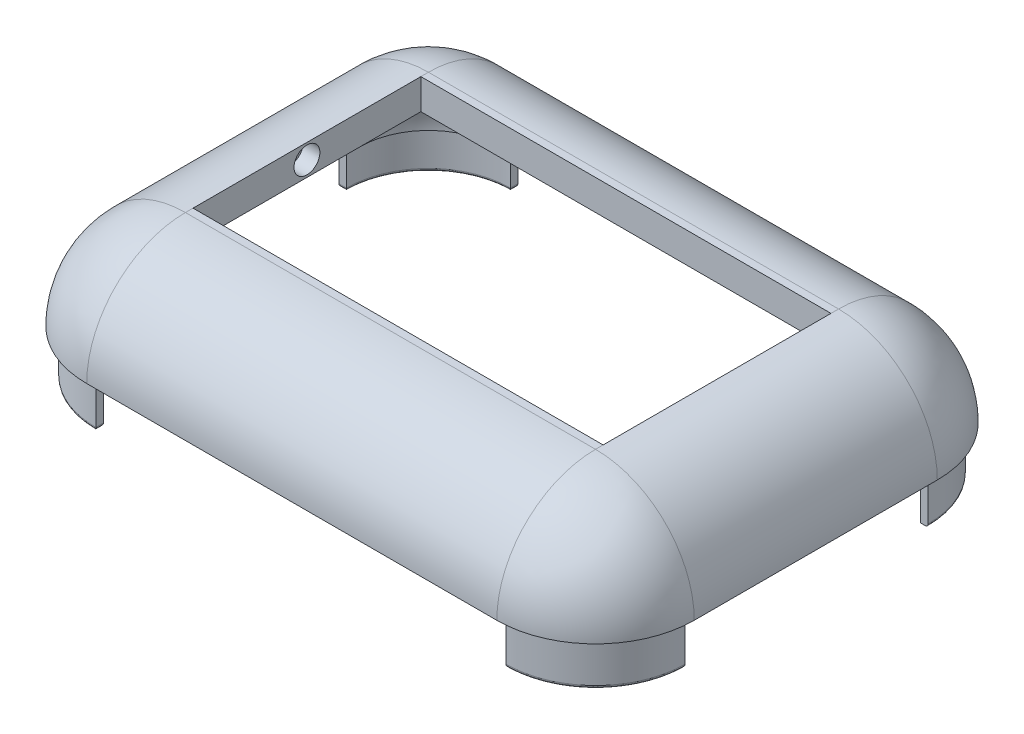
from build123d import *

# Parameters (mm, degrees)
SKETCH1_W           = 40
SKETCH1_H           = 29
BOSS_EXTRUDE1_DEPTH = 20
FILLET2_R           = 6.5
SKETCH3_W           = 48.982601016
SKETCH3_H           = 39.309165856
CUT_EXTRUDE1_DEPTH  = 14.5
SHELL1_T            = -2
BOSS_EXTRUDE3_DEPTH = 3
FILLET3_R           = 0.2
SKETCH6_W           = 27
SKETCH6_H           = 15
CUT_EXTRUDE2_DEPTH  = 10.5000001
SKETCH7_R           = 0.85
CUT_EXTRUDE3_DEPTH  = 1.1
CUT_EXTRUDE4_DEPTH  = 1


with BuildPart() as part:
    # Sketch1 → Boss-Extrude1 (new body)
    with BuildSketch(Plane(origin=(0, 0, 0), x_dir=(1, 0, 0), z_dir=(0, 1, 0))):
        Rectangle(SKETCH1_W, SKETCH1_H)
    extrude(amount=BOSS_EXTRUDE1_DEPTH)

    # Fillet2
    fillet2_edges = [part.edges().sort_by_distance(p)[0] for p in [
        (-20, 20, 0),
        (0, 20, 14.5),
        (20, 20, 0),
        (0, 0, 14.5),
        (-20, 0, 0),
        (0, 0, -14.5),
        (20, 0, 0),
        (20, 10, 14.5),
        (-20, 10, 14.5),
        (-20, 10, -14.5),
        (20, 10, -14.5),
        (0, 20, -14.5),
    ]]
    fillet(fillet2_edges, radius=FILLET2_R)

    # Sketch3 → Cut-Extrude1 (cut, through all)
    with BuildSketch(Plane(origin=(0, 13.5, 0), x_dir=(1, 0, 0), z_dir=(0, 1, 0))):
        Rectangle(SKETCH3_W, SKETCH3_H)
    extrude(amount=-CUT_EXTRUDE1_DEPTH, mode=Mode.SUBTRACT)

    # Shell1
    shell1_openings = [part.faces().sort_by_distance(p)[0] for p in [
        (0, 13.5, 0),
    ]]
    offset(amount=SHELL1_T, openings=shell1_openings)

    # Sketch5 → Boss-Extrude3 (add)
    with BuildSketch(Plane.XZ.offset(-13.5)):
        with BuildLine():
            Line((-13.5, 13.9), (-13.5, 13.4))
            ThreePointArc((-13.5, 13.4), (-17.318376618, 11.818376618), (-18.9, 8))
            Line((-18.9, 8), (-19.4, 8))
            ThreePointArc((-19.4, 8), (-17.671930009, 12.171930009), (-13.5, 13.9))
        make_face()
        with BuildLine():
            Line((-19.4, -8), (-18.9, -8))
            ThreePointArc((-18.9, -8), (-17.318376618, -11.818376618), (-13.5, -13.4))
            Line((-13.5, -13.4), (-13.5, -13.9))
            ThreePointArc((-13.5, -13.9), (-17.671930009, -12.171930009), (-19.4, -8))
        make_face()
        with BuildLine():
            Line((13.5, -13.4), (13.5, -13.9))
            ThreePointArc((13.5, -13.9), (17.671930009, -12.171930009), (19.4, -8))
            Line((19.4, -8), (18.9, -8))
            ThreePointArc((18.9, -8), (17.318376618, -11.818376618), (13.5, -13.4))
        make_face()
        with BuildLine():
            Line((19.4, 8), (18.9, 8))
            ThreePointArc((18.9, 8), (17.318376618, 11.818376618), (13.5, 13.4))
            Line((13.5, 13.4), (13.5, 13.9))
            ThreePointArc((13.5, 13.9), (17.671930009, 12.171930009), (19.4, 8))
        make_face()
    extrude(amount=BOSS_EXTRUDE3_DEPTH)

    # Fillet3
    fillet3_edges = [part.edges().sort_by_distance(p)[0] for p in [
        (-17.318376618, 10.5, 11.818376618),
        (-17.671930009, 10.5, 12.171930009),
        (-17.318376618, 10.5, -11.818376618),
        (-17.671930009, 10.5, -12.171930009),
        (17.318376618, 10.5, 11.818376618),
        (17.671930009, 10.5, 12.171930009),
        (17.671930009, 10.5, -12.171930009),
        (-19.15, 10.5, 8),
        (-13.5, 10.5, 13.65),
        (-13.5, 10.5, -13.65),
        (-19.15, 10.5, -8),
        (13.5, 10.5, 13.65),
        (19.15, 10.5, 8),
    ]]
    fillet(fillet3_edges, radius=FILLET3_R)

    # Sketch6 → Cut-Extrude2 (cut, through all)
    with BuildSketch(Plane(origin=(0, 20, 0), x_dir=(1, 0, 0), z_dir=(0, 1, 0))):
        Rectangle(SKETCH6_W, SKETCH6_H)
    extrude(amount=-CUT_EXTRUDE2_DEPTH, mode=Mode.SUBTRACT)

    # Sketch7 → Cut-Extrude3 (cut)
    with BuildSketch(Plane(origin=(-13.5, 0, 0), x_dir=(0, 0, -1), z_dir=(1, 0, 0))):
        with Locations((0, 19)):
            Circle(SKETCH7_R)
    extrude(amount=-CUT_EXTRUDE3_DEPTH, mode=Mode.SUBTRACT)

    # Sketch9 → Cut-Extrude4 (cut)
    with BuildSketch(Plane.ZY.offset(-13.5)):
        with BuildLine():
            Line((0.85, 19), (0.85, 18))
            Line((0.85, 18), (0.85, 17.368151277))
            Line((0.85, 17.368151277), (-0.85, 17.368151277))
            Line((-0.85, 17.368151277), (-0.85, 18))
            Line((-0.85, 18), (-0.85, 19))
            ThreePointArc((-0.85, 19), (0, 19.85), (0.85, 19))
        make_face()
    extrude(amount=-CUT_EXTRUDE4_DEPTH, mode=Mode.SUBTRACT)


solid = part.part
